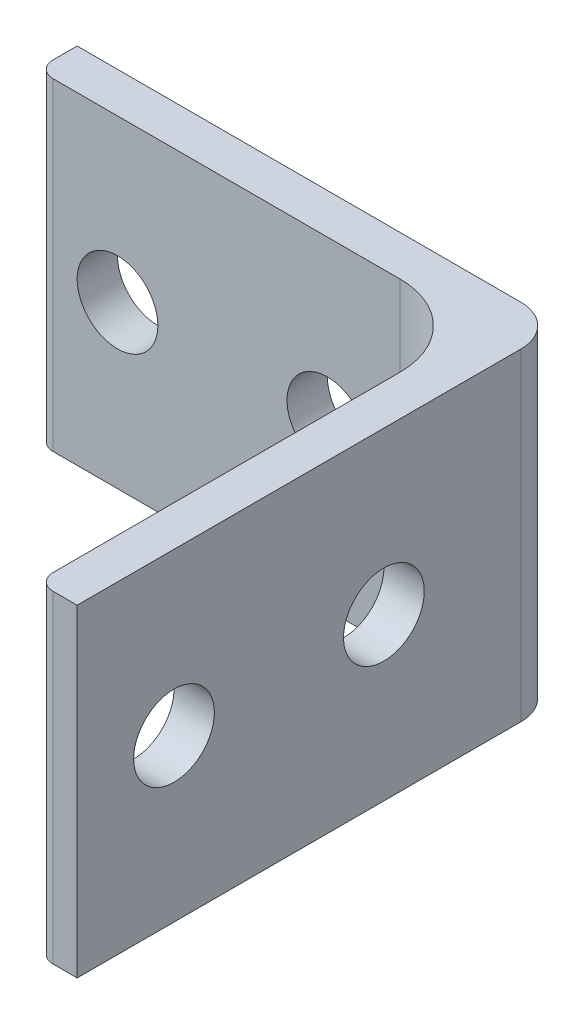
from build123d import *

# Parameters (mm, degrees)
BOSS_EXTRUDE1_DEPTH = 25.4
SKETCH2_R           = 3.175
CUT_EXTRUDE1_DEPTH  = 25.4
SKETCH3_R           = 3.175
CUT_EXTRUDE2_DEPTH  = 25.4


with BuildPart() as part:
    # Sketch1 → Boss-Extrude1 (new body)
    with BuildSketch(Plane(origin=(0, 0, 0), x_dir=(1, 0, 0), z_dir=(0, 1, 0))):
        with BuildLine():
            Line((0, 0), (34.925, 0))
            ThreePointArc((34.925, 0), (37.17006403, -0.92993597), (38.1, -3.175))
            Line((38.1, -3.175), (38.1, -38.1))
            Line((38.1, -38.1), (36.195, -38.1))
            ThreePointArc((36.195, -38.1), (35.296974388, -37.728025612), (34.925, -36.83))
            Line((34.925, -36.83), (34.925, -9.525))
            ThreePointArc((34.925, -9.525), (33.065128061, -5.034871939), (28.575, -3.175))
            Line((28.575, -3.175), (1.27, -3.175))
            ThreePointArc((1.27, -3.175), (0.371974388, -2.803025612), (0, -1.905))
            Line((0, -1.905), (0, 0))
        make_face()
    extrude(amount=-BOSS_EXTRUDE1_DEPTH)

    # Sketch2 → Cut-Extrude1 (cut)
    with BuildSketch(Plane.ZY.offset(-34.925)):
        with Locations((30.48, -12.7)):
            Circle(SKETCH2_R)
        with Locations((13.97, -12.7)):
            Circle(SKETCH2_R)
    extrude(amount=-CUT_EXTRUDE1_DEPTH, mode=Mode.SUBTRACT)

    # Sketch3 → Cut-Extrude2 (cut)
    with BuildSketch(Plane.XY.offset(3.175)):
        with Locations((6.35, -12.7)):
            Circle(SKETCH3_R)
        with Locations((22.86, -12.7)):
            Circle(SKETCH3_R)
    extrude(amount=-CUT_EXTRUDE2_DEPTH, mode=Mode.SUBTRACT)


solid = part.part
